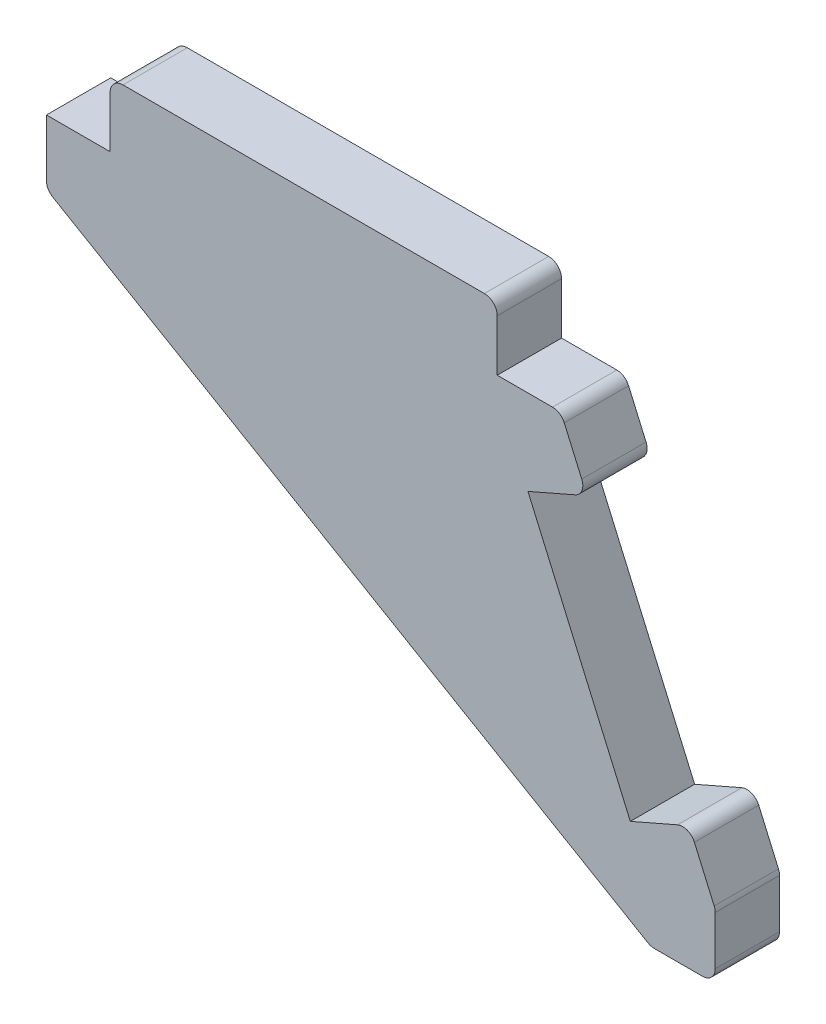
from build123d import *

# Parameters (mm, degrees)
BOSS_EXTRUDE1_DEPTH = 5
FILLET1_R           = 1


with BuildPart() as part:
    # Sketch1 → Boss-Extrude1 (new body)
    with BuildSketch(Plane.XY):
        Polygon((42.02, -4.628401452), (37.437424305, -6.628401452), (45.397424305, -24.867052718), (49.98, -22.867052718), (52, -27.49545417), (52, -32.49545417), (47, -32.49545417), (0, -5), (0, 0), (4.95, 0), (4.95, 5), (35.05, 5), (35.05, 0), (40, 0), align=None)
    extrude(amount=BOSS_EXTRUDE1_DEPTH)

    # Fillet1
    fillet1_edges = [part.edges().sort_by_distance(p)[0] for p in [
        (4.95, 5, 2.5),
        (35.05, 5, 2.5),
        (40, 0, 2.5),
        (42.02, -4.628401452, 2.5),
        (49.98, -22.867052718, 2.5),
        (52, -27.49545417, 2.5),
        (52, -32.49545417, 2.5),
        (47, -32.49545417, 2.5),
        (0, -5, 2.5),
    ]]
    fillet(fillet1_edges, radius=FILLET1_R)


solid = part.part
